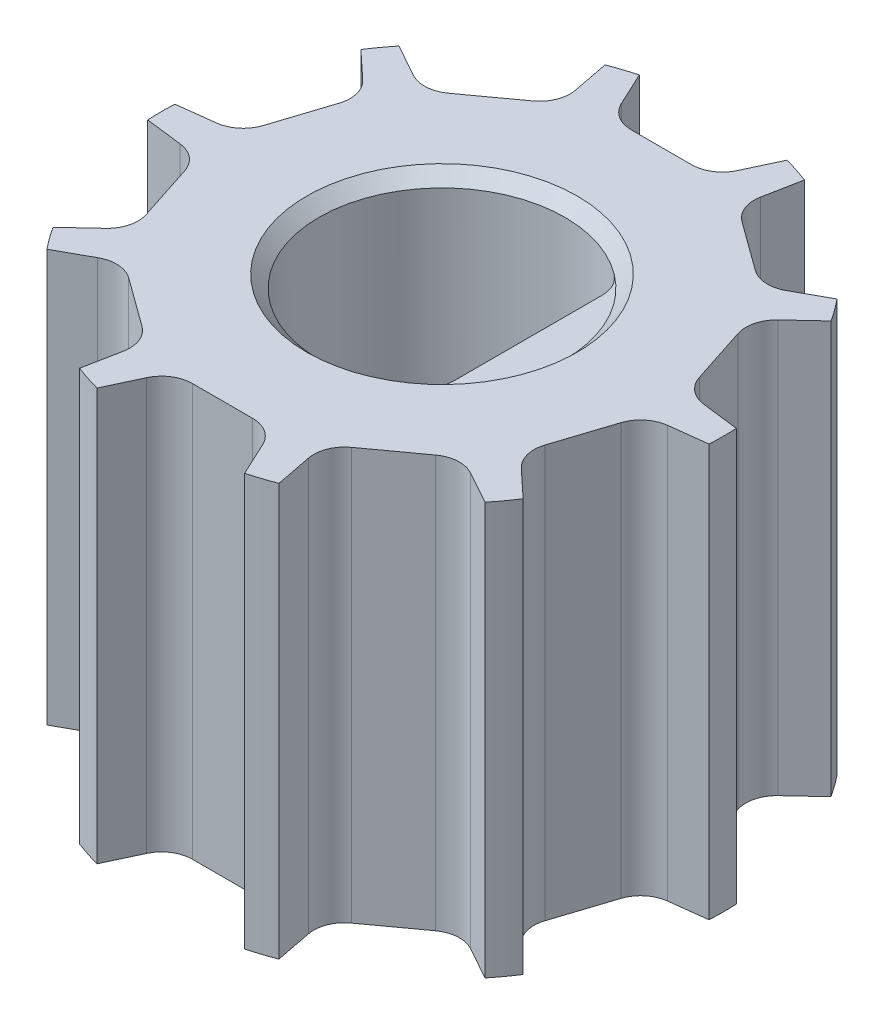
from build123d import *

# Parameters (mm, degrees)
SKIZZE1_R                       = 4.57
SKIZZE1_R_2                     = 2
AUFSATZ_LINEAR_AUSTRAGEN1_DEPTH = 6.7
SCHNITT_LINEAR_AUSTRAGEN1_DEPTH = 7.7
VERRUNDUNG1_R                   = 0.5
KREISMUSTER1_COUNT              = 10
VERRUNDUNG1_OF_KREISMUSTER1_R   = 0.5
FASE2_SIZE                      = 0.2
BOSS_EXTRUDE1_DEPTH             = 3.15
BOSS_EXTRUDE1_DEPTH_BACK        = 3.15
FILLET1_R                       = 0.5


with BuildPart() as part:
    # Skizze1 → Aufsatz-Linear austragen1 (new body)
    with BuildSketch(Plane(origin=(0, 0, 0), x_dir=(1, 0, 0), z_dir=(0, 1, 0))):
        Circle(SKIZZE1_R)
        Circle(SKIZZE1_R_2, mode=Mode.SUBTRACT)
    extrude(amount=AUFSATZ_LINEAR_AUSTRAGEN1_DEPTH)

    # Skizze12 → Schnitt-Linear austragen1 (cut, through all)
    with BuildSketch(Plane(origin=(0, 6.7, 0), x_dir=(1, 0, 0), z_dir=(0, 1, 0))):
        with BuildLine():
            Line((-1.2, 4.409637173), (-0.808470756, 3.57))
            Line((-0.808470756, 3.57), (0.808470756, 3.57))
            Line((0.808470756, 3.57), (1.2, 4.409637173))
            ThreePointArc((1.2, 4.409637173), (0, 4.57), (-1.2, 4.409637173))
        make_face()
    schnitt_linear_austragen1 = extrude(amount=-SCHNITT_LINEAR_AUSTRAGEN1_DEPTH, mode=Mode.SUBTRACT)

    # Verrundung1
    verrundung1_edges = [part.edges().sort_by_distance(p)[0] for p in [
        (0.808470756, 3.35, -3.57),
        (-0.808470756, 3.35, -3.57),
    ]]
    fillet(verrundung1_edges, radius=VERRUNDUNG1_R)

    # Kreismuster1: Schnitt-Linear austragen1 ×10 about axis
    kreismuster1_axis = Axis((0, 0, 0), (0, 1, 0))
    for i in range(1, KREISMUSTER1_COUNT):
        add(schnitt_linear_austragen1.rotate(kreismuster1_axis, i * 360 / KREISMUSTER1_COUNT), mode=Mode.SUBTRACT)

    # Verrundung1 of Kreismuster1
    verrundung1_of_kreismuster1_edges = [part.edges().sort_by_distance(p)[0] for p in [
        (-1.44432677, 3.35, -3.363397857),
        (-2.752459932, 3.35, -2.412983483),
        (-3.14544056, 3.35, -1.872092051),
        (-3.645102966, 3.35, -0.334289289),
        (-3.645102966, 3.35, 0.334289289),
        (-3.14544056, 3.35, 1.872092051),
        (-2.752459932, 3.35, 2.412983483),
        (-1.44432677, 3.35, 3.363397857),
        (-0.808470756, 3.35, 3.57),
        (0.808470756, 3.35, 3.57),
        (1.44432677, 3.35, 3.363397857),
        (2.752459932, 3.35, 2.412983483),
        (3.14544056, 3.35, 1.872092051),
        (3.645102966, 3.35, 0.334289289),
        (3.645102966, 3.35, -0.334289289),
        (3.14544056, 3.35, -1.872092051),
        (2.752459932, 3.35, -2.412983483),
        (1.44432677, 3.35, -3.363397857),
    ]]
    fillet(verrundung1_of_kreismuster1_edges, radius=VERRUNDUNG1_OF_KREISMUSTER1_R)

    # Fase2
    fase2_edges = [part.edges().sort_by_distance(p)[0] for p in [
        (-2, 0, 0),
        (-2, 6.7, 0),
    ]]
    chamfer(fase2_edges, length=FASE2_SIZE)

    # Sketch1 → Boss-Extrude1 (add, two sides)
    with BuildSketch(Plane(origin=(0, 3.35, 0), x_dir=(-1, 0, 0), z_dir=(0, -1, 0))) as boss_extrude1_sk:
        with BuildLine():
            Line((-1.4, 1.428285686), (-1.4, -1.428285686))
            ThreePointArc((-1.4, -1.428285686), (-2, 0), (-1.4, 1.428285686))
        make_face()
    extrude(amount=BOSS_EXTRUDE1_DEPTH)
    extrude(boss_extrude1_sk.sketch, amount=-BOSS_EXTRUDE1_DEPTH_BACK)

    # Fillet1
    fillet1_edges = [part.edges().sort_by_distance(p)[0] for p in [
        (1.4, 3.35, 1.428285686),
        (1.4, 3.35, -1.428285686),
    ]]
    fillet(fillet1_edges, radius=FILLET1_R)


solid = part.part
